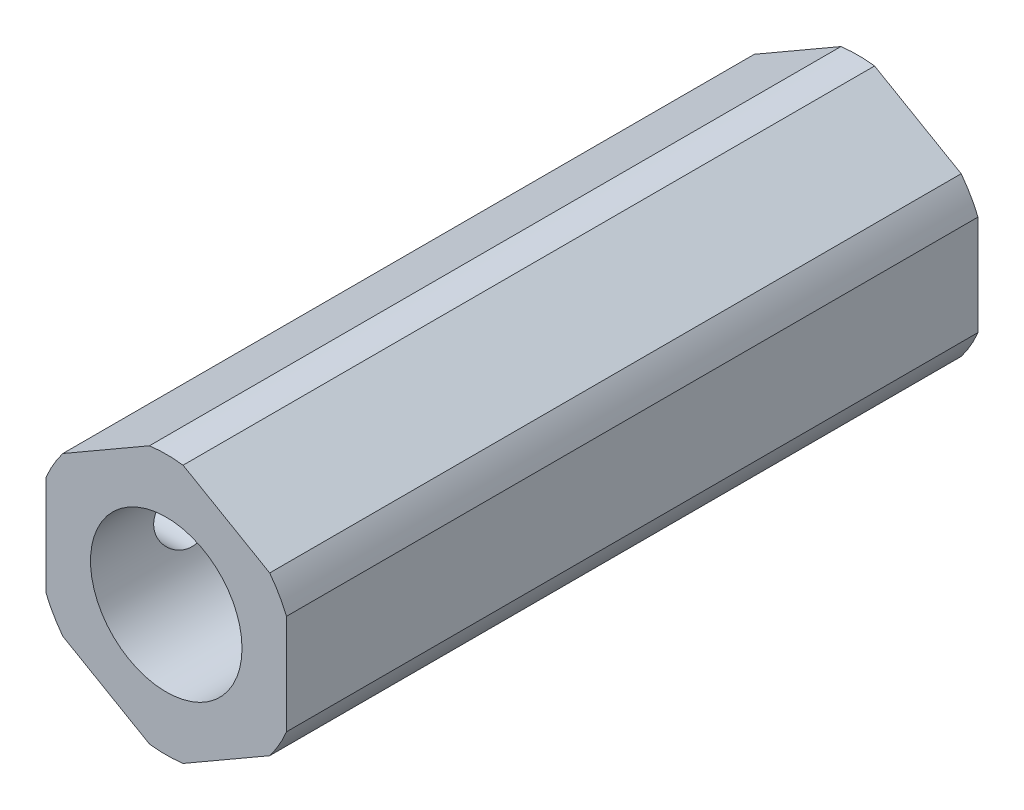
from build123d import *

# Parameters (mm, degrees)
SKETCH1_R               = 6.35
BASIC_ROD_DEPTH         = 18.25625
BASIC_ROD_DEPTH_BACK    = 18.25625
THEX_DEPTH              = 18.25625
SKETCH2_R               = 2.11582
INTERNAL_CUT_DEPTH      = 19.25625
INTERNAL_CUT_DEPTH_BACK = 19.25625
SKETCH9_R               = 4
CUT_EXTRUDE1_DEPTH      = 19.99996
CUT_EXTRUDE2_REACH      = 14.7
SKETCH10_R              = 1.66624


with BuildPart() as part:
    # Sketch1 → Basic Rod (new body, two sides)
    with BuildSketch(Plane.XY) as basic_rod_sk:
        Circle(SKETCH1_R)
    extrude(amount=BASIC_ROD_DEPTH)
    extrude(basic_rod_sk.sketch, amount=-BASIC_ROD_DEPTH_BACK)

    # Sketch8 → THex (add, symmetric)
    with BuildSketch(Plane.XY):
        with BuildLine():
            Line((-0.888411378, 6.819423871), (-5.461588622, 4.179098758))
            ThreePointArc((-5.461588622, 4.179098758), (-5.955700003, 3.438525), (-6.35, 2.640325113))
            Line((-6.35, 2.640325113), (-6.35, -2.640325113))
            ThreePointArc((-6.35, -2.640325113), (-5.955700003, -3.438525), (-5.461588622, -4.179098758))
            Line((-5.461588622, -4.179098758), (-0.888411378, -6.819423871))
            ThreePointArc((-0.888411378, -6.819423871), (0, -6.87705), (0.888411378, -6.819423871))
            Line((0.888411378, -6.819423871), (5.461588622, -4.179098758))
            ThreePointArc((5.461588622, -4.179098758), (5.955700003, -3.438525), (6.35, -2.640325113))
            Line((6.35, -2.640325113), (6.35, 2.640325113))
            ThreePointArc((6.35, 2.640325113), (5.955700003, 3.438525), (5.461588622, 4.179098758))
            Line((5.461588622, 4.179098758), (0.888411378, 6.819423871))
            ThreePointArc((0.888411378, 6.819423871), (0, 6.87705), (-0.888411378, 6.819423871))
        make_face()
    extrude(amount=THEX_DEPTH, both=True)

    # Sketch2 → Internal Cut (cut, two sides)
    with BuildSketch(Plane.XY) as internal_cut_sk:
        Circle(SKETCH2_R)
    extrude(amount=INTERNAL_CUT_DEPTH, mode=Mode.SUBTRACT)
    extrude(internal_cut_sk.sketch, amount=-INTERNAL_CUT_DEPTH_BACK, mode=Mode.SUBTRACT)

    # Sketch9 → Cut-Extrude1 (cut)
    with BuildSketch(Plane.XY.offset(18.25625)):
        Circle(SKETCH9_R)
    extrude(amount=-CUT_EXTRUDE1_DEPTH, mode=Mode.SUBTRACT)

    # Sketch10 → Cut-Extrude2 (cut, up to next)
    with BuildSketch(Plane.ZY.offset(6.35), mode=Mode.PRIVATE) as cut_extrude2_sk1:
        with Locations((5.25399, 0)):
            Circle(SKETCH10_R)
    cut_extrude2_tool1 = extrude(cut_extrude2_sk1.sketch, amount=-CUT_EXTRUDE2_REACH, mode=Mode.PRIVATE) & part.part
    add(cut_extrude2_tool1.solids().sort_by_distance((-6.35, 0, 5.25399))[0], mode=Mode.SUBTRACT)
    # Sketch10 → Cut-Extrude2 (cut, up to next)
    with BuildSketch(Plane.ZY.offset(6.35), mode=Mode.PRIVATE) as cut_extrude2_sk2:
        with Locations((13.25499, 0)):
            Circle(SKETCH10_R)
    cut_extrude2_tool2 = extrude(cut_extrude2_sk2.sketch, amount=-CUT_EXTRUDE2_REACH, mode=Mode.PRIVATE) & part.part
    add(cut_extrude2_tool2.solids().sort_by_distance((-6.35, 0, 13.25499))[0], mode=Mode.SUBTRACT)


solid = part.part
